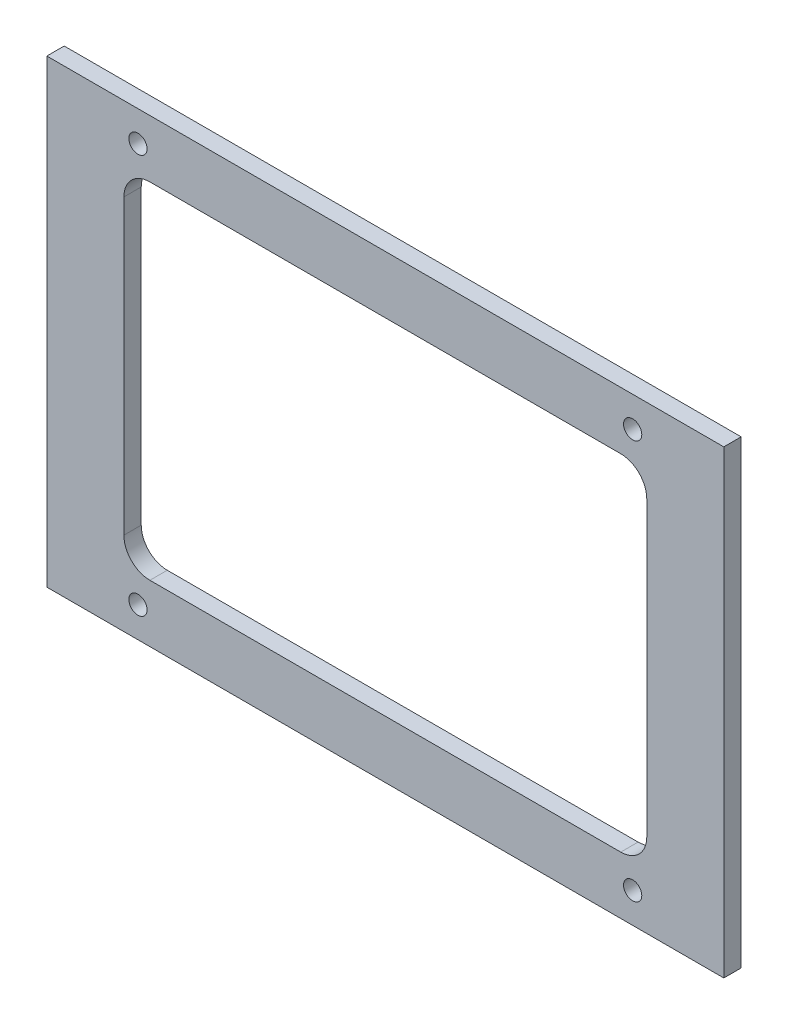
from build123d import *

# Parameters (mm, degrees)
SKETCH1_W           = 156
SKETCH1_H           = 106
BOSS_EXTRUDE1_DEPTH = 4
CUT_EXTRUDE1_REACH  = 96.387


with BuildPart() as part:
    # Sketch1 → Boss-Extrude1 (new body)
    with BuildSketch(Plane.XY):
        Rectangle(SKETCH1_W, SKETCH1_H)
    extrude(amount=-BOSS_EXTRUDE1_DEPTH)

    # Sketch2 → Cut-Extrude1 (cut, up to next)
    with BuildSketch(Plane.XY, mode=Mode.PRIVATE) as cut_extrude1_sk1:
        with BuildLine():
            ThreePointArc((60.25, 33.75), (59.373475383, 36.872498999), (57, 39.082682252))
            Line((57, 39.082682252), (57, -39.082682252))
            ThreePointArc((57, -39.082682252), (59.373475383, -36.872498999), (60.25, -33.75))
            Line((60.25, -33.75), (60.25, 33.75))
        make_face()
    cut_extrude1_tool1 = extrude(cut_extrude1_sk1.sketch, amount=-CUT_EXTRUDE1_REACH, mode=Mode.PRIVATE) & part.part
    # Sketch2 → Cut-Extrude1 (cut, up to next)
    with BuildSketch(Plane.XY, mode=Mode.PRIVATE) as cut_extrude1_sk2:
        with BuildLine():
            ThreePointArc((-54.25, 39.75), (-55.66490397, 39.580784403), (-57, 39.082682252))
            Line((-57, 39.082682252), (-57, -39.082682252))
            ThreePointArc((-57, -39.082682252), (-55.66490397, -39.580784403), (-54.25, -39.75))
            Line((-54.25, -39.75), (54.25, -39.75))
            ThreePointArc((54.25, -39.75), (55.66490397, -39.580784403), (57, -39.082682252))
            Line((57, -39.082682252), (57, 39.082682252))
            ThreePointArc((57, 39.082682252), (55.66490397, 39.580784403), (54.25, 39.75))
            Line((54.25, 39.75), (-54.25, 39.75))
        make_face()
    cut_extrude1_tool2 = extrude(cut_extrude1_sk2.sketch, amount=-CUT_EXTRUDE1_REACH, mode=Mode.PRIVATE) & part.part
    # Sketch2 → Cut-Extrude1 (cut, up to next)
    with BuildSketch(Plane.XY, mode=Mode.PRIVATE) as cut_extrude1_sk3:
        with BuildLine():
            Line((-57, -39.082682252), (-57, 39.082682252))
            ThreePointArc((-57, 39.082682252), (-59.373475383, 36.872498999), (-60.25, 33.75))
            Line((-60.25, 33.75), (-60.25, -33.75))
            ThreePointArc((-60.25, -33.75), (-59.373475383, -36.872498999), (-57, -39.082682252))
        make_face()
    cut_extrude1_tool3 = extrude(cut_extrude1_sk3.sketch, amount=-CUT_EXTRUDE1_REACH, mode=Mode.PRIVATE) & part.part
    # Sketch2 → Cut-Extrude1 (cut, up to next)
    with BuildSketch(Plane.XY, mode=Mode.PRIVATE) as cut_extrude1_sk4:
        with BuildLine():
            ThreePointArc((59.1, 46), (57, 48.1), (54.9, 46))
            Line((54.9, 46), (57, 46))
            Line((57, 46), (57, 43.9))
            ThreePointArc((57, 43.9), (58.48492424, 44.51507576), (59.1, 46))
        make_face()
    cut_extrude1_tool4 = extrude(cut_extrude1_sk4.sketch, amount=-CUT_EXTRUDE1_REACH, mode=Mode.PRIVATE) & part.part
    # Sketch2 → Cut-Extrude1 (cut, up to next)
    with BuildSketch(Plane.XY, mode=Mode.PRIVATE) as cut_extrude1_sk5:
        with BuildLine():
            Line((57, 46), (54.9, 46))
            ThreePointArc((54.9, 46), (55.51507576, 44.51507576), (57, 43.9))
            Line((57, 43.9), (57, 46))
        make_face()
    cut_extrude1_tool5 = extrude(cut_extrude1_sk5.sketch, amount=-CUT_EXTRUDE1_REACH, mode=Mode.PRIVATE) & part.part
    # Sketch2 → Cut-Extrude1 (cut, up to next)
    with BuildSketch(Plane.XY, mode=Mode.PRIVATE) as cut_extrude1_sk6:
        with BuildLine():
            ThreePointArc((59.1, 46), (57, 48.1), (54.9, 46))
            Line((54.9, 46), (57, 46))
            Line((57, 46), (57, 43.9))
            ThreePointArc((57, 43.9), (58.48492424, 44.51507576), (59.1, 46))
        make_face()
    cut_extrude1_tool6 = extrude(cut_extrude1_sk6.sketch, amount=-CUT_EXTRUDE1_REACH, mode=Mode.PRIVATE) & part.part
    # Sketch2 → Cut-Extrude1 (cut, up to next)
    with BuildSketch(Plane.XY, mode=Mode.PRIVATE) as cut_extrude1_sk7:
        with BuildLine():
            Line((57, 46), (54.9, 46))
            ThreePointArc((54.9, 46), (55.51507576, 44.51507576), (57, 43.9))
            Line((57, 43.9), (57, 46))
        make_face()
    cut_extrude1_tool7 = extrude(cut_extrude1_sk7.sketch, amount=-CUT_EXTRUDE1_REACH, mode=Mode.PRIVATE) & part.part
    # Sketch2 → Cut-Extrude1 (cut, up to next)
    with BuildSketch(Plane.XY, mode=Mode.PRIVATE) as cut_extrude1_sk8:
        with BuildLine():
            Line((-57, 43.9), (-57, 46))
            Line((-57, 46), (-54.9, 46))
            ThreePointArc((-54.9, 46), (-58.48492424, 47.48492424), (-57, 43.9))
        make_face()
    cut_extrude1_tool8 = extrude(cut_extrude1_sk8.sketch, amount=-CUT_EXTRUDE1_REACH, mode=Mode.PRIVATE) & part.part
    # Sketch2 → Cut-Extrude1 (cut, up to next)
    with BuildSketch(Plane.XY, mode=Mode.PRIVATE) as cut_extrude1_sk9:
        with BuildLine():
            Line((-54.9, 46), (-57, 46))
            Line((-57, 46), (-57, 43.9))
            ThreePointArc((-57, 43.9), (-55.51507576, 44.51507576), (-54.9, 46))
        make_face()
    cut_extrude1_tool9 = extrude(cut_extrude1_sk9.sketch, amount=-CUT_EXTRUDE1_REACH, mode=Mode.PRIVATE) & part.part
    # Sketch2 → Cut-Extrude1 (cut, up to next)
    with BuildSketch(Plane.XY, mode=Mode.PRIVATE) as cut_extrude1_sk10:
        with BuildLine():
            Line((-57, 43.9), (-57, 46))
            Line((-57, 46), (-54.9, 46))
            ThreePointArc((-54.9, 46), (-58.48492424, 47.48492424), (-57, 43.9))
        make_face()
    cut_extrude1_tool10 = extrude(cut_extrude1_sk10.sketch, amount=-CUT_EXTRUDE1_REACH, mode=Mode.PRIVATE) & part.part
    # Sketch2 → Cut-Extrude1 (cut, up to next)
    with BuildSketch(Plane.XY, mode=Mode.PRIVATE) as cut_extrude1_sk11:
        with BuildLine():
            Line((-54.9, 46), (-57, 46))
            Line((-57, 46), (-57, 43.9))
            ThreePointArc((-57, 43.9), (-55.51507576, 44.51507576), (-54.9, 46))
        make_face()
    cut_extrude1_tool11 = extrude(cut_extrude1_sk11.sketch, amount=-CUT_EXTRUDE1_REACH, mode=Mode.PRIVATE) & part.part
    # Sketch2 → Cut-Extrude1 (cut, up to next)
    with BuildSketch(Plane.XY, mode=Mode.PRIVATE) as cut_extrude1_sk12:
        with BuildLine():
            ThreePointArc((-54.9, -46), (-55.51507576, -44.51507576), (-57, -43.9))
            Line((-57, -43.9), (-57, -46))
            Line((-57, -46), (-54.9, -46))
        make_face()
    cut_extrude1_tool12 = extrude(cut_extrude1_sk12.sketch, amount=-CUT_EXTRUDE1_REACH, mode=Mode.PRIVATE) & part.part
    # Sketch2 → Cut-Extrude1 (cut, up to next)
    with BuildSketch(Plane.XY, mode=Mode.PRIVATE) as cut_extrude1_sk13:
        with BuildLine():
            Line((-57, -46), (-57, -43.9))
            ThreePointArc((-57, -43.9), (-58.48492424, -47.48492424), (-54.9, -46))
            Line((-54.9, -46), (-57, -46))
        make_face()
    cut_extrude1_tool13 = extrude(cut_extrude1_sk13.sketch, amount=-CUT_EXTRUDE1_REACH, mode=Mode.PRIVATE) & part.part
    # Sketch2 → Cut-Extrude1 (cut, up to next)
    with BuildSketch(Plane.XY, mode=Mode.PRIVATE) as cut_extrude1_sk14:
        with BuildLine():
            ThreePointArc((-54.9, -46), (-55.51507576, -44.51507576), (-57, -43.9))
            Line((-57, -43.9), (-57, -46))
            Line((-57, -46), (-54.9, -46))
        make_face()
    cut_extrude1_tool14 = extrude(cut_extrude1_sk14.sketch, amount=-CUT_EXTRUDE1_REACH, mode=Mode.PRIVATE) & part.part
    # Sketch2 → Cut-Extrude1 (cut, up to next)
    with BuildSketch(Plane.XY, mode=Mode.PRIVATE) as cut_extrude1_sk15:
        with BuildLine():
            Line((-57, -46), (-57, -43.9))
            ThreePointArc((-57, -43.9), (-58.48492424, -47.48492424), (-54.9, -46))
            Line((-54.9, -46), (-57, -46))
        make_face()
    cut_extrude1_tool15 = extrude(cut_extrude1_sk15.sketch, amount=-CUT_EXTRUDE1_REACH, mode=Mode.PRIVATE) & part.part
    # Sketch2 → Cut-Extrude1 (cut, up to next)
    with BuildSketch(Plane.XY, mode=Mode.PRIVATE) as cut_extrude1_sk16:
        with BuildLine():
            ThreePointArc((59.1, -46), (58.48492424, -44.51507576), (57, -43.9))
            Line((57, -43.9), (57, -46))
            Line((57, -46), (54.9, -46))
            ThreePointArc((54.9, -46), (57, -48.1), (59.1, -46))
        make_face()
    cut_extrude1_tool16 = extrude(cut_extrude1_sk16.sketch, amount=-CUT_EXTRUDE1_REACH, mode=Mode.PRIVATE) & part.part
    # Sketch2 → Cut-Extrude1 (cut, up to next)
    with BuildSketch(Plane.XY, mode=Mode.PRIVATE) as cut_extrude1_sk17:
        with BuildLine():
            Line((57, -46), (57, -43.9))
            ThreePointArc((57, -43.9), (55.51507576, -44.51507576), (54.9, -46))
            Line((54.9, -46), (57, -46))
        make_face()
    cut_extrude1_tool17 = extrude(cut_extrude1_sk17.sketch, amount=-CUT_EXTRUDE1_REACH, mode=Mode.PRIVATE) & part.part
    # Sketch2 → Cut-Extrude1 (cut, up to next)
    with BuildSketch(Plane.XY, mode=Mode.PRIVATE) as cut_extrude1_sk18:
        with BuildLine():
            ThreePointArc((59.1, -46), (58.48492424, -44.51507576), (57, -43.9))
            Line((57, -43.9), (57, -46))
            Line((57, -46), (54.9, -46))
            ThreePointArc((54.9, -46), (57, -48.1), (59.1, -46))
        make_face()
    cut_extrude1_tool18 = extrude(cut_extrude1_sk18.sketch, amount=-CUT_EXTRUDE1_REACH, mode=Mode.PRIVATE) & part.part
    # Sketch2 → Cut-Extrude1 (cut, up to next)
    with BuildSketch(Plane.XY, mode=Mode.PRIVATE) as cut_extrude1_sk19:
        with BuildLine():
            Line((57, -46), (57, -43.9))
            ThreePointArc((57, -43.9), (55.51507576, -44.51507576), (54.9, -46))
            Line((54.9, -46), (57, -46))
        make_face()
    cut_extrude1_tool19 = extrude(cut_extrude1_sk19.sketch, amount=-CUT_EXTRUDE1_REACH, mode=Mode.PRIVATE) & part.part
    add(cut_extrude1_tool1.solids().sort_by_distance((58.595694, 0, 0))[0], mode=Mode.SUBTRACT)
    add(cut_extrude1_tool2.solids().sort_by_distance((0, 0, 0))[0], mode=Mode.SUBTRACT)
    add(cut_extrude1_tool3.solids().sort_by_distance((-58.595694, 0, 0))[0], mode=Mode.SUBTRACT)
    add(cut_extrude1_tool4.solids().sort_by_distance((57.297089, 46.297089, 0))[0], mode=Mode.SUBTRACT)
    add(cut_extrude1_tool5.solids().sort_by_distance((56.108732, 45.108732, 0))[0], mode=Mode.SUBTRACT)
    add(cut_extrude1_tool6.solids().sort_by_distance((57.297089, 46.297089, 0))[0], mode=Mode.SUBTRACT)
    add(cut_extrude1_tool7.solids().sort_by_distance((56.108732, 45.108732, 0))[0], mode=Mode.SUBTRACT)
    add(cut_extrude1_tool8.solids().sort_by_distance((-57.297089, 46.297089, 0))[0], mode=Mode.SUBTRACT)
    add(cut_extrude1_tool9.solids().sort_by_distance((-56.108732, 45.108732, 0))[0], mode=Mode.SUBTRACT)
    add(cut_extrude1_tool10.solids().sort_by_distance((-57.297089, 46.297089, 0))[0], mode=Mode.SUBTRACT)
    add(cut_extrude1_tool11.solids().sort_by_distance((-56.108732, 45.108732, 0))[0], mode=Mode.SUBTRACT)
    add(cut_extrude1_tool12.solids().sort_by_distance((-56.108732, -45.108732, 0))[0], mode=Mode.SUBTRACT)
    add(cut_extrude1_tool13.solids().sort_by_distance((-57.297089, -46.297089, 0))[0], mode=Mode.SUBTRACT)
    add(cut_extrude1_tool14.solids().sort_by_distance((-56.108732, -45.108732, 0))[0], mode=Mode.SUBTRACT)
    add(cut_extrude1_tool15.solids().sort_by_distance((-57.297089, -46.297089, 0))[0], mode=Mode.SUBTRACT)
    add(cut_extrude1_tool16.solids().sort_by_distance((57.297089, -46.297089, 0))[0], mode=Mode.SUBTRACT)
    add(cut_extrude1_tool17.solids().sort_by_distance((56.108732, -45.108732, 0))[0], mode=Mode.SUBTRACT)
    add(cut_extrude1_tool18.solids().sort_by_distance((57.297089, -46.297089, 0))[0], mode=Mode.SUBTRACT)
    add(cut_extrude1_tool19.solids().sort_by_distance((56.108732, -45.108732, 0))[0], mode=Mode.SUBTRACT)


solid = part.part
